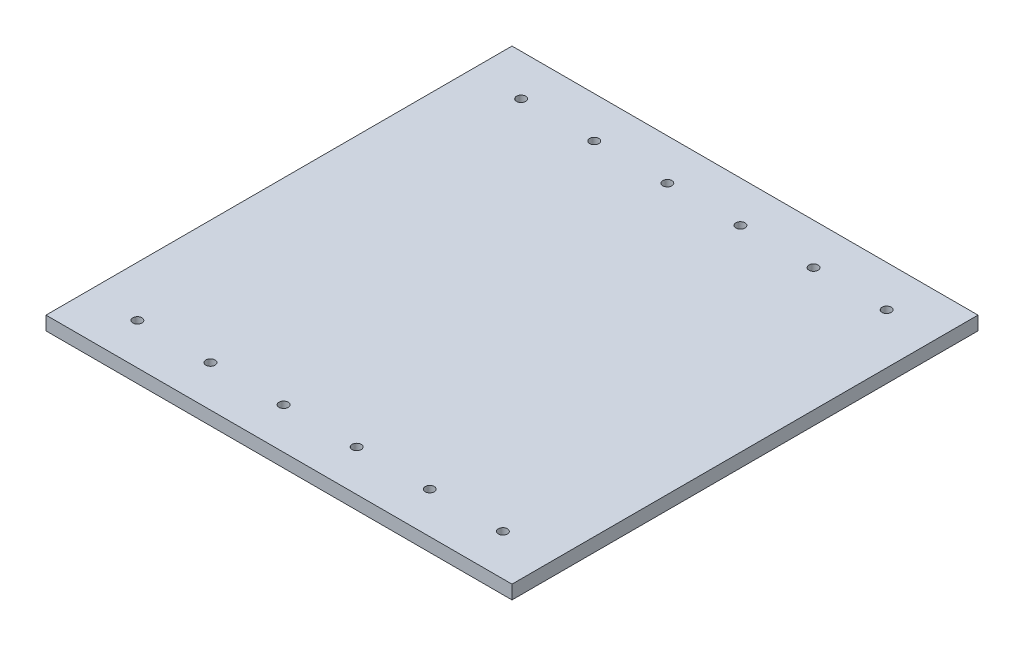
from build123d import *

# Parameters (mm, degrees)
SKETCH1_W           = 647.7
SKETCH1_H           = 647.7
SKETCH1_R           = 6.35
BOSS_EXTRUDE1_DEPTH = 19.05


with BuildPart() as part:
    # Sketch1 → Boss-Extrude1 (new body)
    with BuildSketch(Plane(origin=(0, 0, 0), x_dir=(1, 0, 0), z_dir=(0, 1, 0))):
        with Locations((323.85, -323.85)):
            Rectangle(SKETCH1_W, SKETCH1_H)
        with Locations(Location((69.85, -57.15, 0), (0, 0, 270))):  # turned: the seam where the file's is
            Circle(SKETCH1_R, mode=Mode.SUBTRACT)
        with Locations(Location((171.45, -57.15, 0), (0, 0, 270))):  # turned: the seam where the file's is
            Circle(SKETCH1_R, mode=Mode.SUBTRACT)
        with Locations(Location((273.05, -57.15, 0), (0, 0, 270))):  # turned: the seam where the file's is
            Circle(SKETCH1_R, mode=Mode.SUBTRACT)
        with Locations(Location((374.65, -57.15, 0), (0, 0, 270))):  # turned: the seam where the file's is
            Circle(SKETCH1_R, mode=Mode.SUBTRACT)
        with Locations(Location((476.25, -57.15, 0), (0, 0, 270))):  # turned: the seam where the file's is
            Circle(SKETCH1_R, mode=Mode.SUBTRACT)
        with Locations(Location((577.85, -57.15, 0), (0, 0, 270))):  # turned: the seam where the file's is
            Circle(SKETCH1_R, mode=Mode.SUBTRACT)
        with Locations(Location((69.85, -590.55, 0), (0, 0, 270))):  # turned: the seam where the file's is
            Circle(SKETCH1_R, mode=Mode.SUBTRACT)
        with Locations(Location((171.45, -590.55, 0), (0, 0, 270))):  # turned: the seam where the file's is
            Circle(SKETCH1_R, mode=Mode.SUBTRACT)
        with Locations(Location((273.05, -590.55, 0), (0, 0, 270))):  # turned: the seam where the file's is
            Circle(SKETCH1_R, mode=Mode.SUBTRACT)
        with Locations(Location((374.65, -590.55, 0), (0, 0, 270))):  # turned: the seam where the file's is
            Circle(SKETCH1_R, mode=Mode.SUBTRACT)
        with Locations(Location((476.25, -590.55, 0), (0, 0, 270))):  # turned: the seam where the file's is
            Circle(SKETCH1_R, mode=Mode.SUBTRACT)
        with Locations(Location((577.85, -590.55, 0), (0, 0, 270))):  # turned: the seam where the file's is
            Circle(SKETCH1_R, mode=Mode.SUBTRACT)
    extrude(amount=BOSS_EXTRUDE1_DEPTH)


solid = part.part
